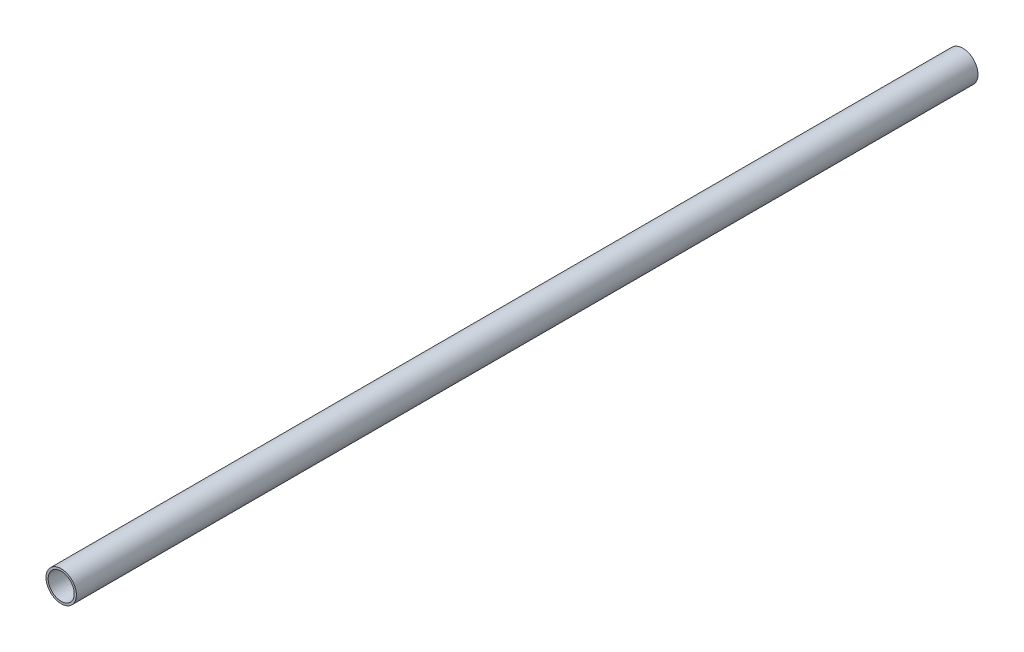
from build123d import *

# Parameters (mm, degrees)
SKETCH1_R           = 7
SKETCH1_R_2         = 6
BOSS_EXTRUDE1_DEPTH = 415


with BuildPart() as part:
    # Sketch1 → Boss-Extrude1 (new body)
    with BuildSketch(Plane.XY):
        Circle(SKETCH1_R)
        Circle(SKETCH1_R_2, mode=Mode.SUBTRACT)
    extrude(amount=BOSS_EXTRUDE1_DEPTH)


solid = part.part
